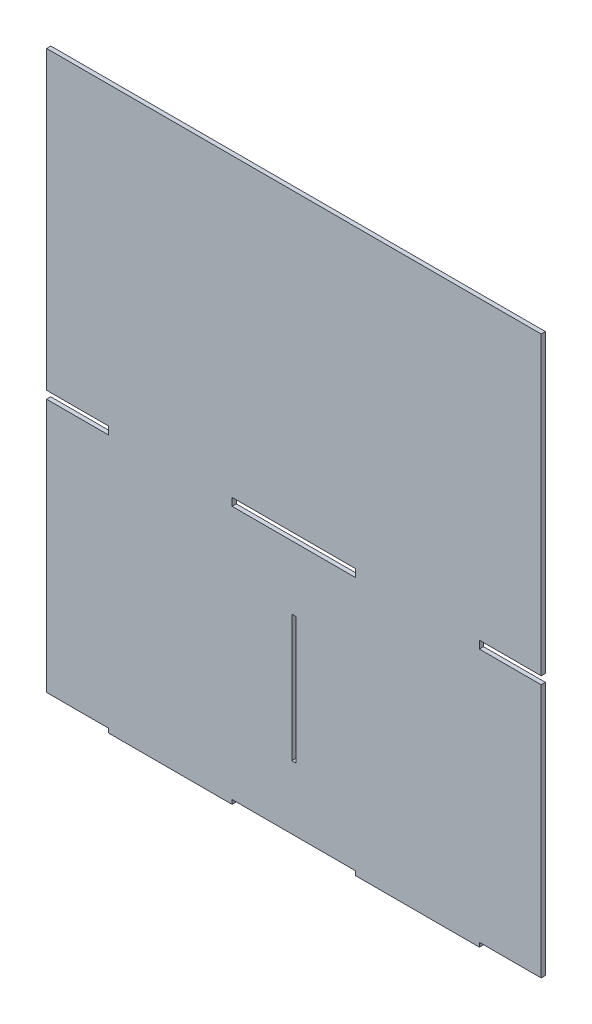
from build123d import *

# Parameters (mm, degrees)
ESBO_O1_W                = 88.020382005
ESBO_O1_H                = 5.5
ESBO_O1_W_2              = 3
ESBO_O1_H_2              = 90.38122327
RESSALTO_EXTRUS_O1_DEPTH = 3


with BuildPart() as part:
    # Esboço1 → Ressalto-extrusão1 (new body)
    with BuildSketch(Plane.XY):
        Polygon((-308.071337018, 0), (-308.071337018, -3), (-220.050955012, -3), (-220.050955012, 0), (-132.031337017, 0), (-132.031337017, -3), (-44.010955012, -3), (-44.010955012, 0), (0, 0), (0, 180.76244654), (-44.010191002, 180.76244654), (-44.010191002, 186.26244654), (0, 186.26244654), (0, 397), (-352.08152802, 397), (-352.08152802, 186.26244654), (-308.071337018, 186.26244654), (-308.071337017, 180.76244654), (-352.08152802, 180.76244654), (-352.08152802, 0), align=None)
        with Locations((-176.04076401, 183.51244654)):
            Rectangle(ESBO_O1_W, ESBO_O1_H, mode=Mode.SUBTRACT)
        with Locations((-176.04076401, 90.38122327)):
            Rectangle(ESBO_O1_W_2, ESBO_O1_H_2, mode=Mode.SUBTRACT)
    extrude(amount=RESSALTO_EXTRUS_O1_DEPTH)


solid = part.part
